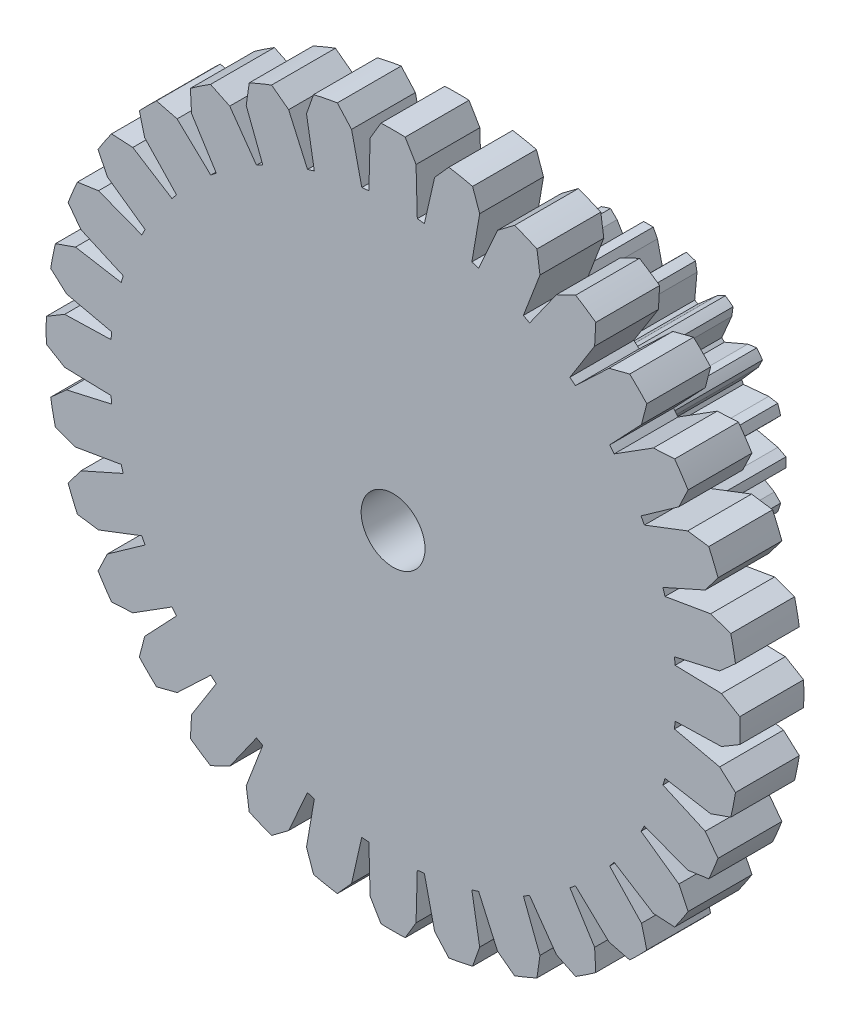
from build123d import *

# Parameters (mm, degrees)
BOSS_EXTRUDE1_DEPTH = 1
SKETCH3_R           = 0.5
CUT_EXTRUDE1_DEPTH  = 1
SKETCH4_R           = 0.5
BOSS_EXTRUDE2_DEPTH = 3


with BuildPart() as part:
    # Sketch2 → Boss-Extrude1 (new body)
    with BuildSketch(Plane.XY):
        with BuildLine():
            Line((-0.359741746, 5.144546649), (-0.379126435, 4.418765455))
            ThreePointArc((-0.379126435, 4.418765455), (-0.434706017, 4.413644263), (-0.490216749, 4.407824014))
            Line((-0.490216749, 4.407824014), (-0.650821853, 5.115877761))
            Line((-0.650821853, 5.115877761), (-0.873635844, 5.364325252))
            ThreePointArc((-0.873635844, 5.364325252), (-1.0603159, 5.330567999), (-1.245704125, 5.29031627))
            Line((-1.245704125, 5.29031627), (-1.356480672, 4.975513495))
            Line((-1.356480672, 4.975513495), (-1.233900002, 4.259896218))
            ThreePointArc((-1.233900002, 4.259896218), (-1.287412544, 4.244030389), (-1.340721178, 4.227492368))
            Line((-1.340721178, 4.227492368), (-1.636374733, 4.890608559))
            Line((-1.636374733, 4.890608559), (-1.903377117, 5.090813349))
            ThreePointArc((-1.903377117, 5.090813349), (-2.079884455, 5.021285259), (-2.253857774, 4.945639507))
            Line((-2.253857774, 4.945639507), (-2.301090806, 4.615274147))
            Line((-2.301090806, 4.615274147), (-2.041255484, 3.937321557))
            ThreePointArc((-2.041255484, 3.937321557), (-2.090644528, 3.911320807), (-2.139702444, 3.884700561))
            Line((-2.139702444, 3.884700561), (-2.55904265, 4.477396013))
            Line((-2.55904265, 4.477396013), (-2.859972675, 4.621664343))
            ThreePointArc((-2.859972675, 4.621664343), (-3.019524216, 4.519037343), (-3.175396933, 4.410904592))
            Line((-3.175396933, 4.410904592), (-3.157271311, 4.077672402))
            Line((-3.157271311, 4.077672402), (-2.770166663, 3.463437838))
            ThreePointArc((-2.770166663, 3.463437838), (-2.813534215, 3.428301361), (-2.856456145, 3.392621891))
            Line((-2.856456145, 3.392621891), (-3.383367994, 3.89211965))
            Line((-3.383367994, 3.89211965), (-3.706661087, 3.974907368))
            ThreePointArc((-3.706661087, 3.974907368), (-3.843125356, 3.843125356), (-3.974907368, 3.706661087))
            Line((-3.974907368, 3.706661087), (-3.89211965, 3.383367994))
            Line((-3.89211965, 3.383367994), (-3.392621891, 2.856456145))
            ThreePointArc((-3.392621891, 2.856456145), (-3.428301361, 2.813534215), (-3.463437838, 2.770166663))
            Line((-3.463437838, 2.770166663), (-4.077672402, 3.157271311))
            Line((-4.077672402, 3.157271311), (-4.410904592, 3.175396933))
            ThreePointArc((-4.410904592, 3.175396933), (-4.519037343, 3.019524216), (-4.621664343, 2.859972675))
            Line((-4.621664343, 2.859972675), (-4.477396013, 2.55904265))
            Line((-4.477396013, 2.55904265), (-3.884700561, 2.139702444))
            ThreePointArc((-3.884700561, 2.139702444), (-3.911320807, 2.090644528), (-3.937321557, 2.041255484))
            Line((-3.937321557, 2.041255484), (-4.615274147, 2.301090806))
            Line((-4.615274147, 2.301090806), (-4.945639507, 2.253857774))
            ThreePointArc((-4.945639507, 2.253857774), (-5.021285259, 2.079884455), (-5.090813349, 1.903377117))
            Line((-5.090813349, 1.903377117), (-4.890608559, 1.636374733))
            Line((-4.890608559, 1.636374733), (-4.227492368, 1.340721178))
            ThreePointArc((-4.227492368, 1.340721178), (-4.244030389, 1.287412544), (-4.259896218, 1.233900002))
            Line((-4.259896218, 1.233900002), (-4.975513495, 1.356480672))
            Line((-4.975513495, 1.356480672), (-5.29031627, 1.245704125))
            ThreePointArc((-5.29031627, 1.245704125), (-5.330567999, 1.0603159), (-5.364325252, 0.873635844))
            Line((-5.364325252, 0.873635844), (-5.115877761, 0.650821853))
            Line((-5.115877761, 0.650821853), (-4.407824014, 0.490216749))
            ThreePointArc((-4.407824014, 0.490216749), (-4.413644263, 0.434706017), (-4.418765455, 0.379126435))
            Line((-4.418765455, 0.379126435), (-5.144546649, 0.359741746))
            Line((-5.144546649, 0.359741746), (-5.431689145, 0.189678765))
            ThreePointArc((-5.431689145, 0.189678765), (-5.435, 0), (-5.431689145, -0.189678765))
            Line((-5.431689145, -0.189678765), (-5.144546649, -0.359741746))
            Line((-5.144546649, -0.359741746), (-4.418765455, -0.379126435))
            ThreePointArc((-4.418765455, -0.379126435), (-4.413644263, -0.434706017), (-4.407824014, -0.490216749))
            Line((-4.407824014, -0.490216749), (-5.115877761, -0.650821853))
            Line((-5.115877761, -0.650821853), (-5.364325252, -0.873635844))
            ThreePointArc((-5.364325252, -0.873635844), (-5.330567999, -1.0603159), (-5.29031627, -1.245704125))
            Line((-5.29031627, -1.245704125), (-4.975513495, -1.356480672))
            Line((-4.975513495, -1.356480672), (-4.259896218, -1.233900002))
            ThreePointArc((-4.259896218, -1.233900002), (-4.244030389, -1.287412544), (-4.227492368, -1.340721178))
            Line((-4.227492368, -1.340721178), (-4.890608559, -1.636374733))
            Line((-4.890608559, -1.636374733), (-5.090813349, -1.903377117))
            ThreePointArc((-5.090813349, -1.903377117), (-5.021285259, -2.079884455), (-4.945639507, -2.253857774))
            Line((-4.945639507, -2.253857774), (-4.615274147, -2.301090806))
            Line((-4.615274147, -2.301090806), (-3.937321557, -2.041255484))
            ThreePointArc((-3.937321557, -2.041255484), (-3.911320807, -2.090644528), (-3.884700561, -2.139702444))
            Line((-3.884700561, -2.139702444), (-4.477396013, -2.55904265))
            Line((-4.477396013, -2.55904265), (-4.621664343, -2.859972675))
            ThreePointArc((-4.621664343, -2.859972675), (-4.519037343, -3.019524216), (-4.410904592, -3.175396933))
            Line((-4.410904592, -3.175396933), (-4.077672402, -3.157271311))
            Line((-4.077672402, -3.157271311), (-3.463437838, -2.770166663))
            ThreePointArc((-3.463437838, -2.770166663), (-3.428301361, -2.813534215), (-3.392621891, -2.856456145))
            Line((-3.392621891, -2.856456145), (-3.89211965, -3.383367994))
            Line((-3.89211965, -3.383367994), (-3.974907368, -3.706661087))
            ThreePointArc((-3.974907368, -3.706661087), (-3.843125356, -3.843125356), (-3.706661087, -3.974907368))
            Line((-3.706661087, -3.974907368), (-3.383367994, -3.89211965))
            Line((-3.383367994, -3.89211965), (-2.856456145, -3.392621891))
            ThreePointArc((-2.856456145, -3.392621891), (-2.813534215, -3.428301361), (-2.770166663, -3.463437838))
            Line((-2.770166663, -3.463437838), (-3.157271311, -4.077672402))
            Line((-3.157271311, -4.077672402), (-3.175396933, -4.410904592))
            ThreePointArc((-3.175396933, -4.410904592), (-3.019524216, -4.519037343), (-2.859972675, -4.621664343))
            Line((-2.859972675, -4.621664343), (-2.55904265, -4.477396013))
            Line((-2.55904265, -4.477396013), (-2.139702444, -3.884700561))
            ThreePointArc((-2.139702444, -3.884700561), (-2.090644528, -3.911320807), (-2.041255484, -3.937321557))
            Line((-2.041255484, -3.937321557), (-2.301090806, -4.615274147))
            Line((-2.301090806, -4.615274147), (-2.253857774, -4.945639507))
            ThreePointArc((-2.253857774, -4.945639507), (-2.079884455, -5.021285259), (-1.903377117, -5.090813349))
            Line((-1.903377117, -5.090813349), (-1.636374733, -4.890608559))
            Line((-1.636374733, -4.890608559), (-1.340721178, -4.227492368))
            ThreePointArc((-1.340721178, -4.227492368), (-1.287412544, -4.244030389), (-1.233900002, -4.259896218))
            Line((-1.233900002, -4.259896218), (-1.356480672, -4.975513495))
            Line((-1.356480672, -4.975513495), (-1.245704125, -5.29031627))
            ThreePointArc((-1.245704125, -5.29031627), (-1.0603159, -5.330567999), (-0.873635844, -5.364325252))
            Line((-0.873635844, -5.364325252), (-0.650821853, -5.115877761))
            Line((-0.650821853, -5.115877761), (-0.490216749, -4.407824014))
            ThreePointArc((-0.490216749, -4.407824014), (-0.434706017, -4.413644263), (-0.379126435, -4.418765455))
            Line((-0.379126435, -4.418765455), (-0.359741746, -5.144546649))
            Line((-0.359741746, -5.144546649), (-0.189678765, -5.431689145))
            ThreePointArc((-0.189678765, -5.431689145), (0, -5.435), (0.189678765, -5.431689145))
            Line((0.189678765, -5.431689145), (0.359741746, -5.144546649))
            Line((0.359741746, -5.144546649), (0.379126435, -4.418765455))
            ThreePointArc((0.379126435, -4.418765455), (0.434706017, -4.413644263), (0.490216749, -4.407824014))
            Line((0.490216749, -4.407824014), (0.650821853, -5.115877761))
            Line((0.650821853, -5.115877761), (0.873635844, -5.364325252))
            ThreePointArc((0.873635844, -5.364325252), (1.0603159, -5.330567999), (1.245704125, -5.29031627))
            Line((1.245704125, -5.29031627), (1.356480672, -4.975513495))
            Line((1.356480672, -4.975513495), (1.233900002, -4.259896218))
            ThreePointArc((1.233900002, -4.259896218), (1.287412544, -4.244030389), (1.340721178, -4.227492368))
            Line((1.340721178, -4.227492368), (1.636374733, -4.890608559))
            Line((1.636374733, -4.890608559), (1.903377117, -5.090813349))
            ThreePointArc((1.903377117, -5.090813349), (2.079884455, -5.021285259), (2.253857774, -4.945639507))
            Line((2.253857774, -4.945639507), (2.301090806, -4.615274147))
            Line((2.301090806, -4.615274147), (2.041255484, -3.937321557))
            ThreePointArc((2.041255484, -3.937321557), (2.090644528, -3.911320807), (2.139702444, -3.884700561))
            Line((2.139702444, -3.884700561), (2.55904265, -4.477396013))
            Line((2.55904265, -4.477396013), (2.859972675, -4.621664343))
            ThreePointArc((2.859972675, -4.621664343), (3.019524216, -4.519037343), (3.175396933, -4.410904592))
            Line((3.175396933, -4.410904592), (3.157271311, -4.077672402))
            Line((3.157271311, -4.077672402), (2.770166663, -3.463437838))
            ThreePointArc((2.770166663, -3.463437838), (2.813534215, -3.428301361), (2.856456145, -3.392621891))
            Line((2.856456145, -3.392621891), (3.383367994, -3.89211965))
            Line((3.383367994, -3.89211965), (3.706661087, -3.974907368))
            ThreePointArc((3.706661087, -3.974907368), (3.843125356, -3.843125356), (3.974907368, -3.706661087))
            Line((3.974907368, -3.706661087), (3.89211965, -3.383367994))
            Line((3.89211965, -3.383367994), (3.392621891, -2.856456145))
            ThreePointArc((3.392621891, -2.856456145), (3.428301361, -2.813534215), (3.463437838, -2.770166663))
            Line((3.463437838, -2.770166663), (4.077672402, -3.157271311))
            Line((4.077672402, -3.157271311), (4.410904592, -3.175396933))
            ThreePointArc((4.410904592, -3.175396933), (4.519037343, -3.019524216), (4.621664343, -2.859972675))
            Line((4.621664343, -2.859972675), (4.477396013, -2.55904265))
            Line((4.477396013, -2.55904265), (3.884700561, -2.139702444))
            ThreePointArc((3.884700561, -2.139702444), (3.911320807, -2.090644528), (3.937321557, -2.041255484))
            Line((3.937321557, -2.041255484), (4.615274147, -2.301090806))
            Line((4.615274147, -2.301090806), (4.945639507, -2.253857774))
            ThreePointArc((4.945639507, -2.253857774), (5.021285259, -2.079884455), (5.090813349, -1.903377117))
            Line((5.090813349, -1.903377117), (4.890608559, -1.636374733))
            Line((4.890608559, -1.636374733), (4.227492368, -1.340721178))
            ThreePointArc((4.227492368, -1.340721178), (4.244030389, -1.287412544), (4.259896218, -1.233900002))
            Line((4.259896218, -1.233900002), (4.975513495, -1.356480672))
            Line((4.975513495, -1.356480672), (5.29031627, -1.245704125))
            ThreePointArc((5.29031627, -1.245704125), (5.330567999, -1.0603159), (5.364325252, -0.873635844))
            Line((5.364325252, -0.873635844), (5.115877761, -0.650821853))
            Line((5.115877761, -0.650821853), (4.407824014, -0.490216749))
            ThreePointArc((4.407824014, -0.490216749), (4.413644263, -0.434706017), (4.418765455, -0.379126435))
            Line((4.418765455, -0.379126435), (5.144546649, -0.359741746))
            Line((5.144546649, -0.359741746), (5.431689145, -0.189678765))
            ThreePointArc((5.431689145, -0.189678765), (5.435, 0), (5.431689145, 0.189678765))
            Line((5.431689145, 0.189678765), (5.144546649, 0.359741746))
            Line((5.144546649, 0.359741746), (4.418765455, 0.379126435))
            ThreePointArc((4.418765455, 0.379126435), (4.413644263, 0.434706017), (4.407824014, 0.490216749))
            Line((4.407824014, 0.490216749), (5.115877761, 0.650821853))
            Line((5.115877761, 0.650821853), (5.364325252, 0.873635844))
            ThreePointArc((5.364325252, 0.873635844), (5.330567999, 1.0603159), (5.29031627, 1.245704125))
            Line((5.29031627, 1.245704125), (4.975513495, 1.356480672))
            Line((4.975513495, 1.356480672), (4.259896218, 1.233900002))
            ThreePointArc((4.259896218, 1.233900002), (4.244030389, 1.287412544), (4.227492368, 1.340721178))
            Line((4.227492368, 1.340721178), (4.890608559, 1.636374733))
            Line((4.890608559, 1.636374733), (5.090813349, 1.903377117))
            ThreePointArc((5.090813349, 1.903377117), (5.021285259, 2.079884455), (4.945639507, 2.253857774))
            Line((4.945639507, 2.253857774), (4.615274147, 2.301090806))
            Line((4.615274147, 2.301090806), (3.937321557, 2.041255484))
            ThreePointArc((3.937321557, 2.041255484), (3.911320807, 2.090644528), (3.884700561, 2.139702444))
            Line((3.884700561, 2.139702444), (4.477396013, 2.55904265))
            Line((4.477396013, 2.55904265), (4.621664343, 2.859972675))
            ThreePointArc((4.621664343, 2.859972675), (4.519037343, 3.019524216), (4.410904592, 3.175396933))
            Line((4.410904592, 3.175396933), (4.077672402, 3.157271311))
            Line((4.077672402, 3.157271311), (3.463437838, 2.770166663))
            ThreePointArc((3.463437838, 2.770166663), (3.428301361, 2.813534215), (3.392621891, 2.856456145))
            Line((3.392621891, 2.856456145), (3.89211965, 3.383367994))
            Line((3.89211965, 3.383367994), (3.974907368, 3.706661087))
            ThreePointArc((3.974907368, 3.706661087), (3.843125356, 3.843125356), (3.706661087, 3.974907368))
            Line((3.706661087, 3.974907368), (3.383367994, 3.89211965))
            Line((3.383367994, 3.89211965), (2.856456145, 3.392621891))
            ThreePointArc((2.856456145, 3.392621891), (2.813534215, 3.428301361), (2.770166663, 3.463437838))
            Line((2.770166663, 3.463437838), (3.157271311, 4.077672402))
            Line((3.157271311, 4.077672402), (3.175396933, 4.410904592))
            ThreePointArc((3.175396933, 4.410904592), (3.019524216, 4.519037343), (2.859972675, 4.621664343))
            Line((2.859972675, 4.621664343), (2.55904265, 4.477396013))
            Line((2.55904265, 4.477396013), (2.139702444, 3.884700561))
            ThreePointArc((2.139702444, 3.884700561), (2.090644528, 3.911320807), (2.041255484, 3.937321557))
            Line((2.041255484, 3.937321557), (2.301090806, 4.615274147))
            Line((2.301090806, 4.615274147), (2.253857774, 4.945639507))
            ThreePointArc((2.253857774, 4.945639507), (2.079884455, 5.021285259), (1.903377117, 5.090813349))
            Line((1.903377117, 5.090813349), (1.636374733, 4.890608559))
            Line((1.636374733, 4.890608559), (1.340721178, 4.227492368))
            ThreePointArc((1.340721178, 4.227492368), (1.287412544, 4.244030389), (1.233900002, 4.259896218))
            Line((1.233900002, 4.259896218), (1.356480672, 4.975513495))
            Line((1.356480672, 4.975513495), (1.245704125, 5.29031627))
            ThreePointArc((1.245704125, 5.29031627), (1.0603159, 5.330567999), (0.873635844, 5.364325252))
            Line((0.873635844, 5.364325252), (0.650821853, 5.115877761))
            Line((0.650821853, 5.115877761), (0.490216749, 4.407824014))
            ThreePointArc((0.490216749, 4.407824014), (0.434706017, 4.413644263), (0.379126435, 4.418765455))
            Line((0.379126435, 4.418765455), (0.359741746, 5.144546649))
            Line((0.359741746, 5.144546649), (0.189678765, 5.431689145))
            ThreePointArc((0.189678765, 5.431689145), (0, 5.435), (-0.189678765, 5.431689145))
            Line((-0.189678765, 5.431689145), (-0.359741746, 5.144546649))
        make_face()
    extrude(amount=BOSS_EXTRUDE1_DEPTH)

    # Sketch3 → Cut-Extrude1 (cut)
    with BuildSketch(Plane.XY.offset(1)):
        Circle(SKETCH3_R)
    extrude(amount=-CUT_EXTRUDE1_DEPTH, mode=Mode.SUBTRACT)

    # Sketch4 → Boss-Extrude2 (add)
    with BuildSketch(Plane(origin=(0, 0, 0), x_dir=(-1, 0, 0), z_dir=(0, 0, -1))):
        with BuildLine():
            Line((0.737053409, 2.025037598), (0.761166089, 1.88395218))
            Line((0.761166089, 1.88395218), (0.725504248, 1.487504147))
            ThreePointArc((0.725504248, 1.487504147), (0.751354277, 1.474615798), (0.776975436, 1.461278266))
            Line((0.776975436, 1.461278266), (1.076747129, 1.723155609))
            Line((1.076747129, 1.723155609), (1.205060707, 1.786575969))
            ThreePointArc((1.205060707, 1.786575969), (1.266677219, 1.743431623), (1.326750479, 1.698163174))
            Line((1.326750479, 1.698163174), (1.306085209, 1.55653174))
            Line((1.306085209, 1.55653174), (1.149659603, 1.19050737))
            ThreePointArc((1.149659603, 1.19050737), (1.170261723, 1.170261723), (1.19050737, 1.149659603))
            Line((1.19050737, 1.149659603), (1.55653174, 1.306085209))
            Line((1.55653174, 1.306085209), (1.698163174, 1.326750479))
            ThreePointArc((1.698163174, 1.326750479), (1.743431623, 1.266677219), (1.786575969, 1.205060707))
            Line((1.786575969, 1.205060707), (1.723155609, 1.076747129))
            Line((1.723155609, 1.076747129), (1.461278266, 0.776975436))
            ThreePointArc((1.461278266, 0.776975436), (1.474615798, 0.751354277), (1.487504147, 0.725504248))
            Line((1.487504147, 0.725504248), (1.88395218, 0.761166089))
            Line((1.88395218, 0.761166089), (2.025037598, 0.737053409))
            ThreePointArc((2.025037598, 0.737053409), (2.049526793, 0.665931623), (2.071518955, 0.593998502))
            Line((2.071518955, 0.593998502), (1.971551532, 0.491563006))
            Line((1.971551532, 0.491563006), (1.629856831, 0.287387734))
            ThreePointArc((1.629856831, 0.287387734), (1.634624204, 0.25889904), (1.638893654, 0.230331482))
            Line((1.638893654, 0.230331482), (2.026958254, 0.141738729))
            Line((2.026958254, 0.141738729), (2.153687232, 0.075208415))
            ThreePointArc((2.153687232, 0.075208415), (2.155, 0), (2.153687232, -0.075208415))
            Line((2.153687232, -0.075208415), (2.026958254, -0.141738729))
            Line((2.026958254, -0.141738729), (1.638893654, -0.230331482))
            ThreePointArc((1.638893654, -0.230331482), (1.634624204, -0.25889904), (1.629856831, -0.287387734))
            Line((1.629856831, -0.287387734), (1.971551532, -0.491563006))
            Line((1.971551532, -0.491563006), (2.071518955, -0.593998502))
            ThreePointArc((2.071518955, -0.593998502), (2.049526793, -0.665931623), (2.025037598, -0.737053409))
            Line((2.025037598, -0.737053409), (1.88395218, -0.761166089))
            Line((1.88395218, -0.761166089), (1.487504147, -0.725504248))
            ThreePointArc((1.487504147, -0.725504248), (1.474615798, -0.751354277), (1.461278266, -0.776975436))
            Line((1.461278266, -0.776975436), (1.723155609, -1.076747129))
            Line((1.723155609, -1.076747129), (1.786575969, -1.205060707))
            ThreePointArc((1.786575969, -1.205060707), (1.743431623, -1.266677219), (1.698163174, -1.326750479))
            Line((1.698163174, -1.326750479), (1.55653174, -1.306085209))
            Line((1.55653174, -1.306085209), (1.19050737, -1.149659603))
            ThreePointArc((1.19050737, -1.149659603), (1.170261723, -1.170261723), (1.149659603, -1.19050737))
            Line((1.149659603, -1.19050737), (1.306085209, -1.55653174))
            Line((1.306085209, -1.55653174), (1.326750479, -1.698163174))
            ThreePointArc((1.326750479, -1.698163174), (1.266677219, -1.743431623), (1.205060707, -1.786575969))
            Line((1.205060707, -1.786575969), (1.076747129, -1.723155609))
            Line((1.076747129, -1.723155609), (0.776975436, -1.461278266))
            ThreePointArc((0.776975436, -1.461278266), (0.751354277, -1.474615798), (0.725504248, -1.487504147))
            Line((0.725504248, -1.487504147), (0.761166089, -1.88395218))
            Line((0.761166089, -1.88395218), (0.737053409, -2.025037598))
            ThreePointArc((0.737053409, -2.025037598), (0.665931623, -2.049526793), (0.593998502, -2.071518955))
            Line((0.593998502, -2.071518955), (0.491563006, -1.971551532))
            Line((0.491563006, -1.971551532), (0.287387734, -1.629856831))
            ThreePointArc((0.287387734, -1.629856831), (0.25889904, -1.634624204), (0.230331482, -1.638893654))
            Line((0.230331482, -1.638893654), (0.141738729, -2.026958254))
            Line((0.141738729, -2.026958254), (0.075208415, -2.153687232))
            ThreePointArc((0.075208415, -2.153687232), (0, -2.155), (-0.075208415, -2.153687232))
            Line((-0.075208415, -2.153687232), (-0.141738729, -2.026958254))
            Line((-0.141738729, -2.026958254), (-0.230331482, -1.638893654))
            ThreePointArc((-0.230331482, -1.638893654), (-0.25889904, -1.634624204), (-0.287387734, -1.629856831))
            Line((-0.287387734, -1.629856831), (-0.491563006, -1.971551532))
            Line((-0.491563006, -1.971551532), (-0.593998502, -2.071518955))
            ThreePointArc((-0.593998502, -2.071518955), (-0.665931623, -2.049526793), (-0.737053409, -2.025037598))
            Line((-0.737053409, -2.025037598), (-0.761166089, -1.88395218))
            Line((-0.761166089, -1.88395218), (-0.725504248, -1.487504147))
            ThreePointArc((-0.725504248, -1.487504147), (-0.972784593, -1.338923126), (-1.19050737, -1.149659603))
            Line((-1.19050737, -1.149659603), (-1.55653174, -1.306085209))
            Line((-1.55653174, -1.306085209), (-1.698163174, -1.326750479))
            ThreePointArc((-1.698163174, -1.326750479), (-1.743431623, -1.266677219), (-1.786575969, -1.205060707))
            Line((-1.786575969, -1.205060707), (-1.723155609, -1.076747129))
            Line((-1.723155609, -1.076747129), (-1.461278266, -0.776975436))
            ThreePointArc((-1.461278266, -0.776975436), (-1.474615798, -0.751354277), (-1.487504147, -0.725504248))
            Line((-1.487504147, -0.725504248), (-1.88395218, -0.761166089))
            Line((-1.88395218, -0.761166089), (-2.025037598, -0.737053409))
            ThreePointArc((-2.025037598, -0.737053409), (-2.049526793, -0.665931623), (-2.071518955, -0.593998502))
            Line((-2.071518955, -0.593998502), (-1.971551532, -0.491563006))
            Line((-1.971551532, -0.491563006), (-1.629856831, -0.287387734))
            ThreePointArc((-1.629856831, -0.287387734), (-1.634624204, -0.25889904), (-1.638893654, -0.230331482))
            Line((-1.638893654, -0.230331482), (-2.026958254, -0.141738729))
            Line((-2.026958254, -0.141738729), (-2.153687232, -0.075208415))
            ThreePointArc((-2.153687232, -0.075208415), (-2.155, 0), (-2.153687232, 0.075208415))
            Line((-2.153687232, 0.075208415), (-2.026958254, 0.141738729))
            Line((-2.026958254, 0.141738729), (-1.638893654, 0.230331482))
            ThreePointArc((-1.638893654, 0.230331482), (-1.634624204, 0.25889904), (-1.629856831, 0.287387734))
            Line((-1.629856831, 0.287387734), (-1.971551532, 0.491563006))
            Line((-1.971551532, 0.491563006), (-2.071518955, 0.593998502))
            ThreePointArc((-2.071518955, 0.593998502), (-2.049526793, 0.665931623), (-2.025037598, 0.737053409))
            Line((-2.025037598, 0.737053409), (-1.88395218, 0.761166089))
            Line((-1.88395218, 0.761166089), (-1.487504147, 0.725504248))
            ThreePointArc((-1.487504147, 0.725504248), (-1.474615798, 0.751354277), (-1.461278266, 0.776975436))
            Line((-1.461278266, 0.776975436), (-1.723155609, 1.076747129))
            Line((-1.723155609, 1.076747129), (-1.786575969, 1.205060707))
            ThreePointArc((-1.786575969, 1.205060707), (-1.743431623, 1.266677219), (-1.698163174, 1.326750479))
            Line((-1.698163174, 1.326750479), (-1.55653174, 1.306085209))
            Line((-1.55653174, 1.306085209), (-1.19050737, 1.149659603))
            ThreePointArc((-1.19050737, 1.149659603), (-1.170261723, 1.170261723), (-1.149659603, 1.19050737))
            Line((-1.149659603, 1.19050737), (-1.306085209, 1.55653174))
            Line((-1.306085209, 1.55653174), (-1.326750479, 1.698163174))
            ThreePointArc((-1.326750479, 1.698163174), (-1.266677219, 1.743431623), (-1.205060707, 1.786575969))
            Line((-1.205060707, 1.786575969), (-1.076747129, 1.723155609))
            Line((-1.076747129, 1.723155609), (-0.776975436, 1.461278266))
            ThreePointArc((-0.776975436, 1.461278266), (-0.751354277, 1.474615798), (-0.725504248, 1.487504147))
            Line((-0.725504248, 1.487504147), (-0.761166089, 1.88395218))
            Line((-0.761166089, 1.88395218), (-0.737053409, 2.025037598))
            ThreePointArc((-0.737053409, 2.025037598), (-0.665931623, 2.049526793), (-0.593998502, 2.071518955))
            Line((-0.593998502, 2.071518955), (-0.491563006, 1.971551532))
            Line((-0.491563006, 1.971551532), (-0.287387734, 1.629856831))
            ThreePointArc((-0.287387734, 1.629856831), (-0.25889904, 1.634624204), (-0.230331482, 1.638893654))
            Line((-0.230331482, 1.638893654), (-0.141738729, 2.026958254))
            Line((-0.141738729, 2.026958254), (-0.075208415, 2.153687232))
            ThreePointArc((-0.075208415, 2.153687232), (0, 2.155), (0.075208415, 2.153687232))
            Line((0.075208415, 2.153687232), (0.141738729, 2.026958254))
            Line((0.141738729, 2.026958254), (0.230331482, 1.638893654))
            ThreePointArc((0.230331482, 1.638893654), (0.25889904, 1.634624204), (0.287387734, 1.629856831))
            Line((0.287387734, 1.629856831), (0.491563006, 1.971551532))
            Line((0.491563006, 1.971551532), (0.593998502, 2.071518955))
            ThreePointArc((0.593998502, 2.071518955), (0.665931623, 2.049526793), (0.737053409, 2.025037598))
        make_face()
        with Locations(Location((0, 0, 0), (0, 0, 180))):
            Circle(SKETCH4_R, mode=Mode.SUBTRACT)
    extrude(amount=BOSS_EXTRUDE2_DEPTH)


solid = part.part
